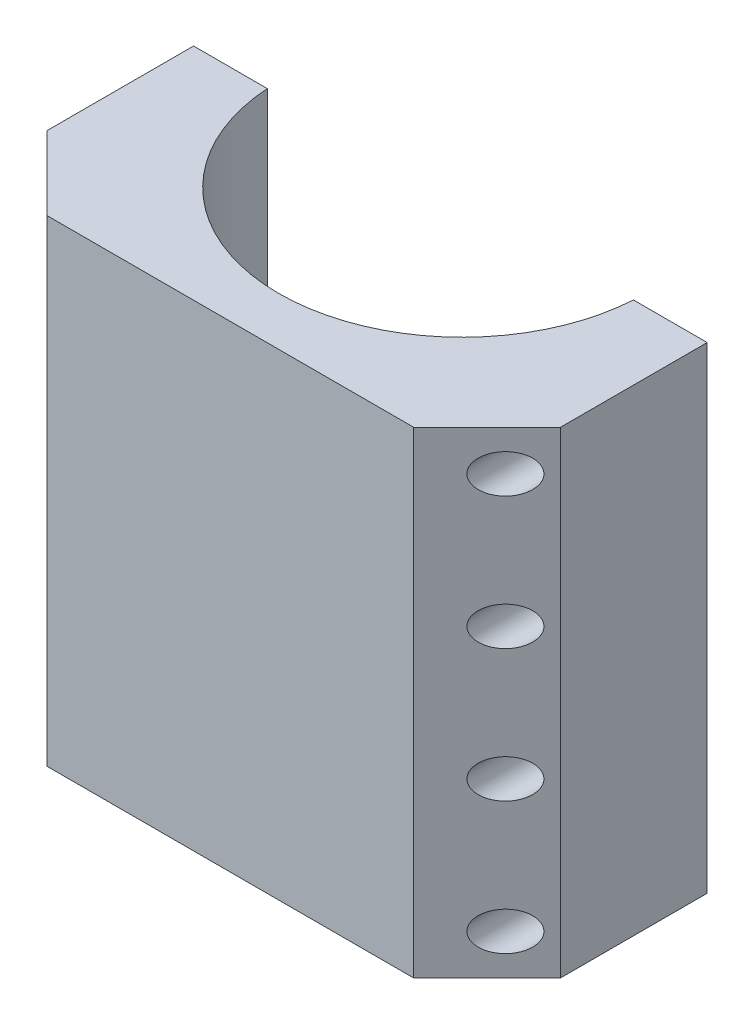
from build123d import *

# Parameters (mm, degrees)
SKETCH_1_W          = 140
SKETCH_1_H          = 130
EXTRUDE_1_DEPTH     = 60
CHAMFER_1_SIZE      = 20
SKETCH_2_R          = 50
CUT_EXTRUDE_1_DEPTH = 131
SKETCH_7_R          = 3
CUT_EXTRUDE_2_DEPTH = 61
SKETCH_8_R          = 5.25
CUT_EXTRUDE_3_DEPTH = 35


with BuildPart() as part:
    # 草图1 → 凸台-拉伸1 (new body)
    with BuildSketch(Plane.XY):
        with Locations((70, -65)):
            Rectangle(SKETCH_1_W, SKETCH_1_H)
    extrude(amount=EXTRUDE_1_DEPTH)

    # 倒角1
    chamfer_1_edges = [part.edges().sort_by_distance(p)[0] for p in [
        (140, -65, 60),
        (0, -65, 60),
    ]]
    chamfer(chamfer_1_edges, length=CHAMFER_1_SIZE)

    # 草图2 → 切除-拉伸1 (cut, through all)
    with BuildSketch(Plane(origin=(0, 0, 0), x_dir=(1, 0, 0), z_dir=(0, 1, 0))):
        with Locations((70, 3.2)):
            Circle(SKETCH_2_R)
    extrude(amount=-CUT_EXTRUDE_1_DEPTH, mode=Mode.SUBTRACT)

    # 草图7 → 切除-拉伸2 (cut, through all)
    with BuildSketch(Plane.XY.offset(60)):
        with Locations((7.5, -11)):
            Circle(SKETCH_7_R)
        with Locations((132.5, -11)):
            Circle(SKETCH_7_R)
        with Locations((132.5, -47)):
            Circle(SKETCH_7_R)
        with Locations((132.5, -83)):
            Circle(SKETCH_7_R)
        with Locations((132.5, -119)):
            Circle(SKETCH_7_R)
        with Locations((7.5, -47)):
            Circle(SKETCH_7_R)
        with Locations((7.5, -83)):
            Circle(SKETCH_7_R)
        with Locations((7.5, -119)):
            Circle(SKETCH_7_R)
    extrude(amount=-CUT_EXTRUDE_2_DEPTH, mode=Mode.SUBTRACT)

    # 草图8 → 切除-拉伸3 (cut)
    with BuildSketch(Plane.XY.offset(60)):
        with Locations((7.5, -11)):
            Circle(SKETCH_8_R)
        with Locations((132.5, -11)):
            Circle(SKETCH_8_R)
        with Locations((132.5, -47)):
            Circle(SKETCH_8_R)
        with Locations((132.5, -83)):
            Circle(SKETCH_8_R)
        with Locations((132.5, -119)):
            Circle(SKETCH_8_R)
        with Locations((7.5, -47)):
            Circle(SKETCH_8_R)
        with Locations((7.5, -83)):
            Circle(SKETCH_8_R)
        with Locations((7.5, -119)):
            Circle(SKETCH_8_R)
    extrude(amount=-CUT_EXTRUDE_3_DEPTH, mode=Mode.SUBTRACT)


solid = part.part
